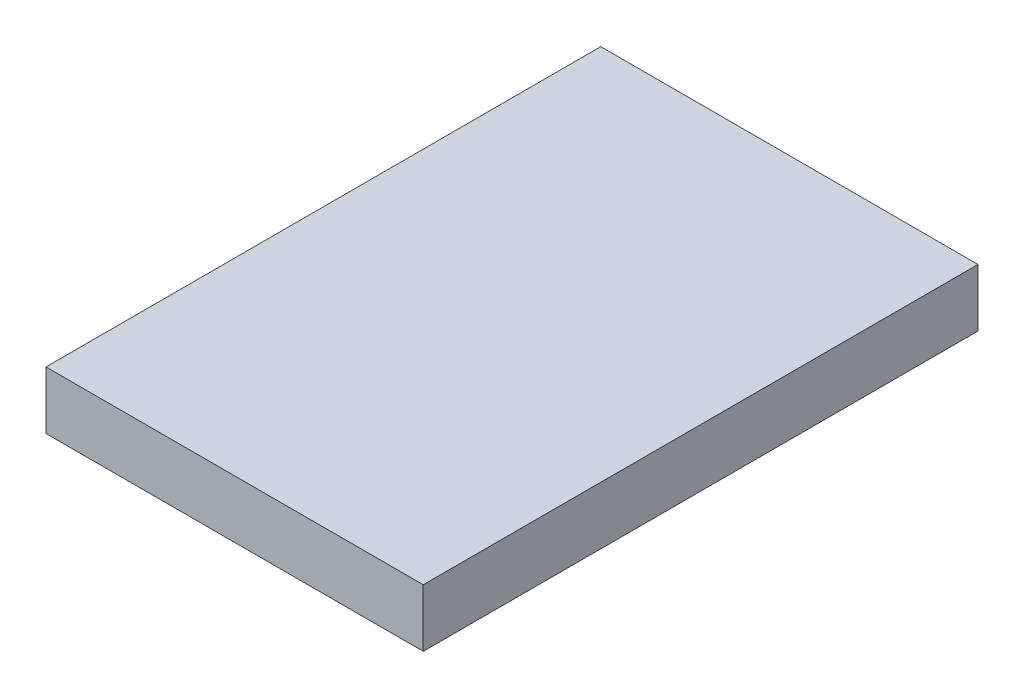
from build123d import *

# Parameters (mm, degrees)
SKETCH1_W           = 34
SKETCH1_H           = 50
BOSS_EXTRUDE1_DEPTH = 5.2


with BuildPart() as part:
    # Sketch1 → Boss-Extrude1 (new body)
    with BuildSketch(Plane(origin=(0, 0, 0), x_dir=(1, 0, 0), z_dir=(0, 1, 0))):
        with Locations((17, 25)):
            Rectangle(SKETCH1_W, SKETCH1_H)
    extrude(amount=BOSS_EXTRUDE1_DEPTH)


solid = part.part
